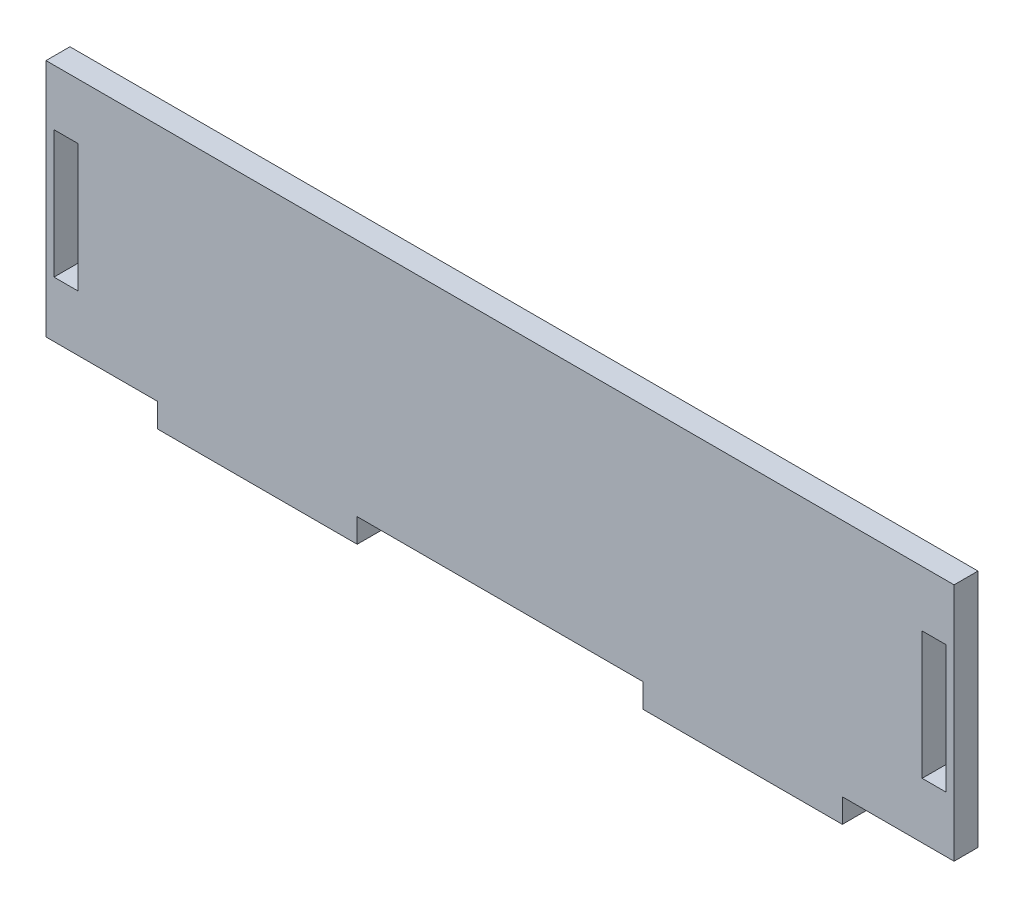
from build123d import *

# Parameters (mm, degrees)
SKETCH_2_W      = 3
SKETCH_2_H      = 16
EXTRUDE_1_DEPTH = 3


with BuildPart() as part:
    # 草图2 → 凸台-拉伸1 (new body)
    with BuildSketch(Plane.XY):
        Polygon((41.5, 0), (59.4, 0), (77.3, 0), (77.3, -3), (102.3, -3), (102.3, 0), (112.3, 0), (116.3, 0), (116.3, 30), (112.3, 30), (6.5, 30), (2.5, 30), (2.5, 0), (6.5, 0), (16.5, 0), (16.5, -3), (41.5, -3), align=None)
        with Locations((5, 15)):
            Rectangle(SKETCH_2_W, SKETCH_2_H, mode=Mode.SUBTRACT)
        Polygon((112.3, 15), (112.3, 23), (115.3, 23), (115.3, 7), (112.3, 7), align=None, mode=Mode.SUBTRACT)
    extrude(amount=EXTRUDE_1_DEPTH)


solid = part.part
